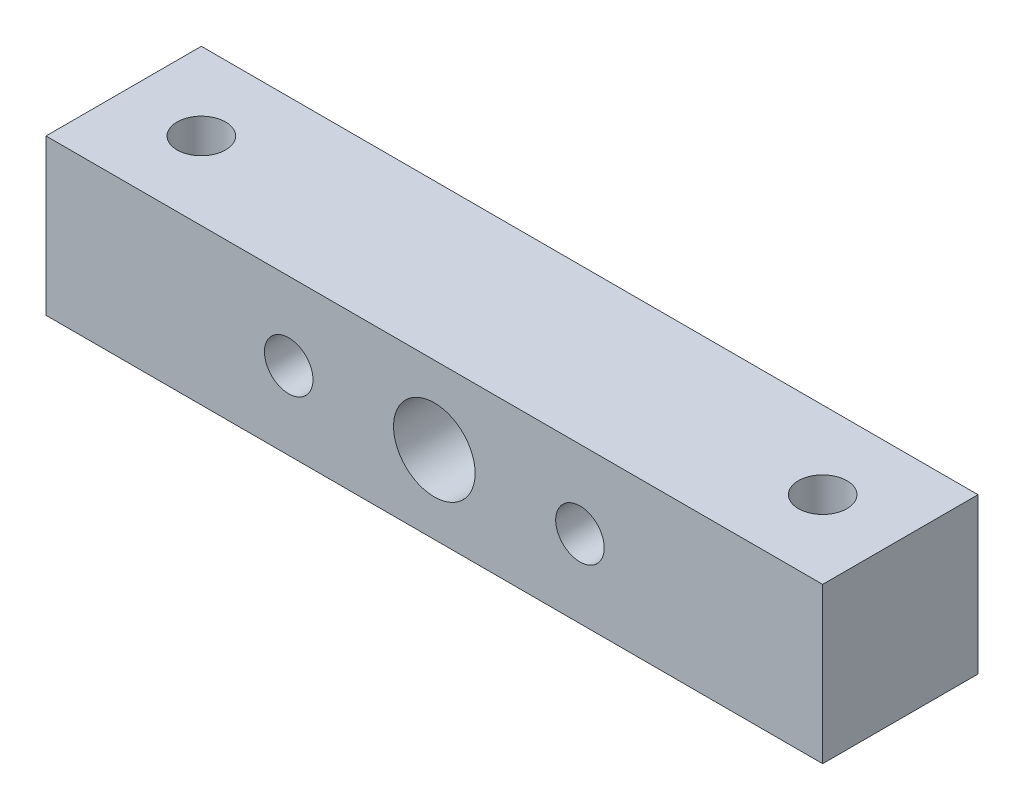
from build123d import *

# Parameters (mm, degrees)
SKETCH1_W           = 40
SKETCH1_H           = 8
SKETCH1_R           = 2.1
SKETCH1_R_2         = 1.25
BOSS_EXTRUDE1_DEPTH = 8
SKETCH2_R           = 1.25
CUT_EXTRUDE1_DEPTH  = 9


with BuildPart() as part:
    # Sketch1 → Boss-Extrude1 (new body)
    with BuildSketch(Plane.XY):
        Rectangle(SKETCH1_W, SKETCH1_H)
        Circle(SKETCH1_R, mode=Mode.SUBTRACT)
        with Locations((7.5, 0)):
            Circle(SKETCH1_R_2, mode=Mode.SUBTRACT)
        with Locations((-7.5, 0)):
            Circle(SKETCH1_R_2, mode=Mode.SUBTRACT)
    extrude(amount=BOSS_EXTRUDE1_DEPTH)

    # Sketch2 → Cut-Extrude1 (cut, through all)
    with BuildSketch(Plane.XZ.offset(4)):
        with Locations((-16, 4)):
            Circle(SKETCH2_R)
        with Locations((16, 4)):
            Circle(SKETCH2_R)
    extrude(amount=-CUT_EXTRUDE1_DEPTH, mode=Mode.SUBTRACT)


solid = part.part
